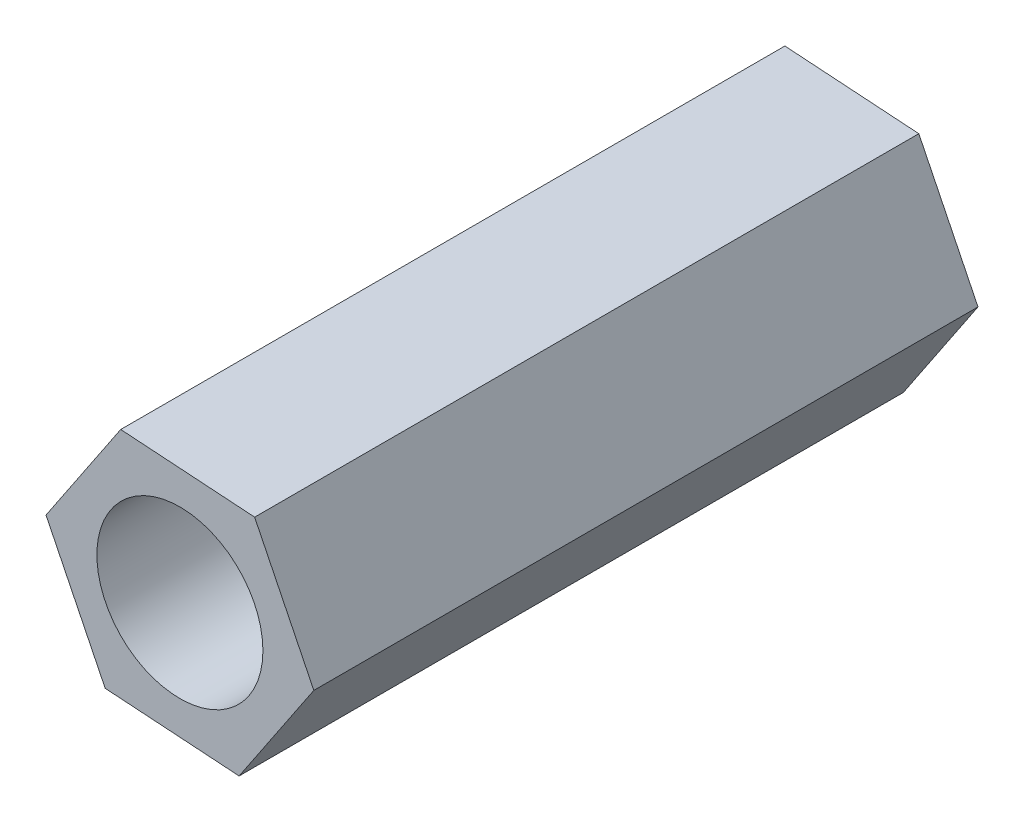
from build123d import *

# Parameters (mm, degrees)
SKETCH1_R           = 2.5
BOSS_EXTRUDE1_DEPTH = 20


with BuildPart() as part:
    # Sketch1 → Boss-Extrude1 (new body)
    with BuildSketch(Plane.XY):
        Polygon((1.782333739, -3.627205505), (4.032418982, -0.270056456), (2.250085242, 3.357149049), (-1.782333739, 3.627205505), (-4.032418982, 0.270056456), (-2.250085242, -3.357149049), align=None)
        Circle(SKETCH1_R, mode=Mode.SUBTRACT)
    extrude(amount=BOSS_EXTRUDE1_DEPTH)


solid = part.part
